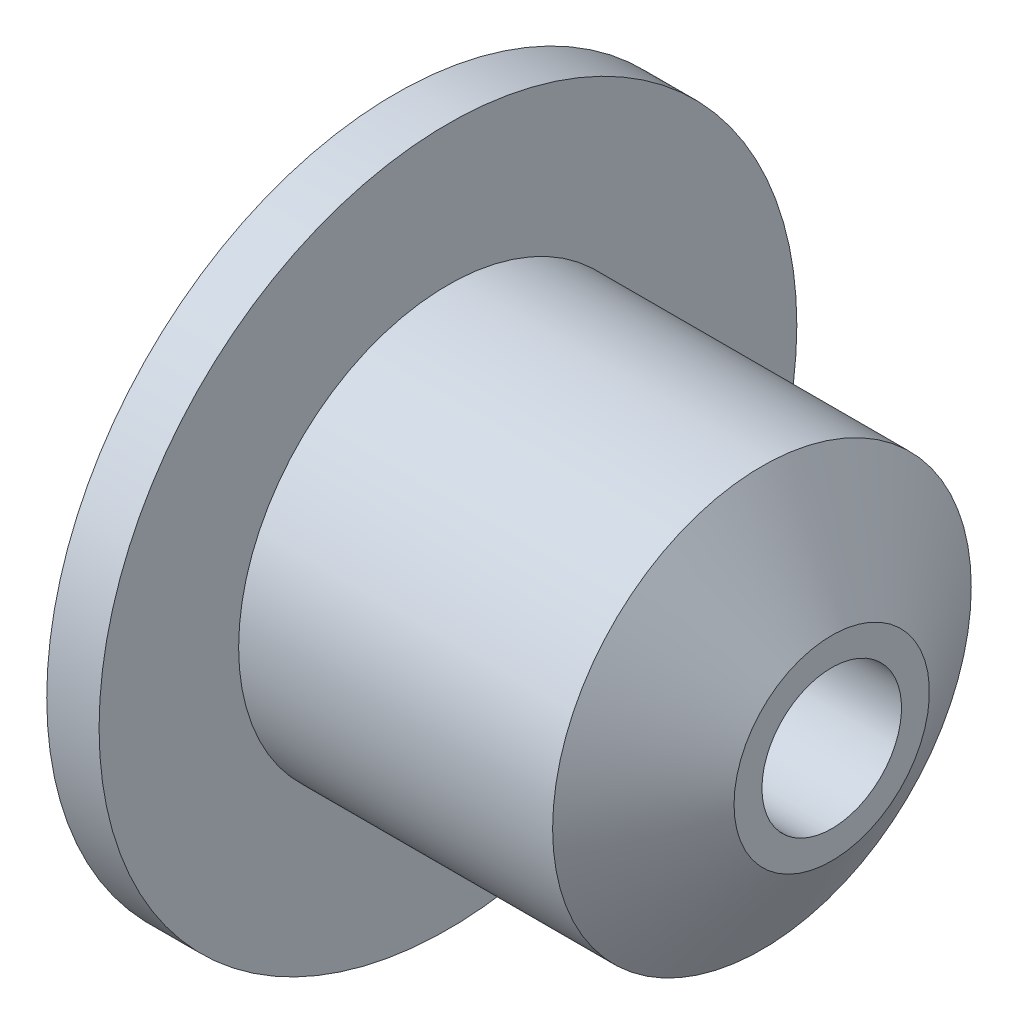
from build123d import *


with BuildPart() as part:
    # 草图1 → 旋转1 (revolve)
    with BuildSketch(Plane.XY):
        Polygon((-34.925752115, 2), (-34.925752115, 10), (-33.425752115, 10), (-33.425752115, 6), (-24.425752115, 6), (-22.425752115, 2.8), (-22.425752115, 2), (-24.425752115, 2), align=None)
    revolve(axis=Axis((-41.136073604, 0, 0), (1, 0, 0)))


solid = part.part
